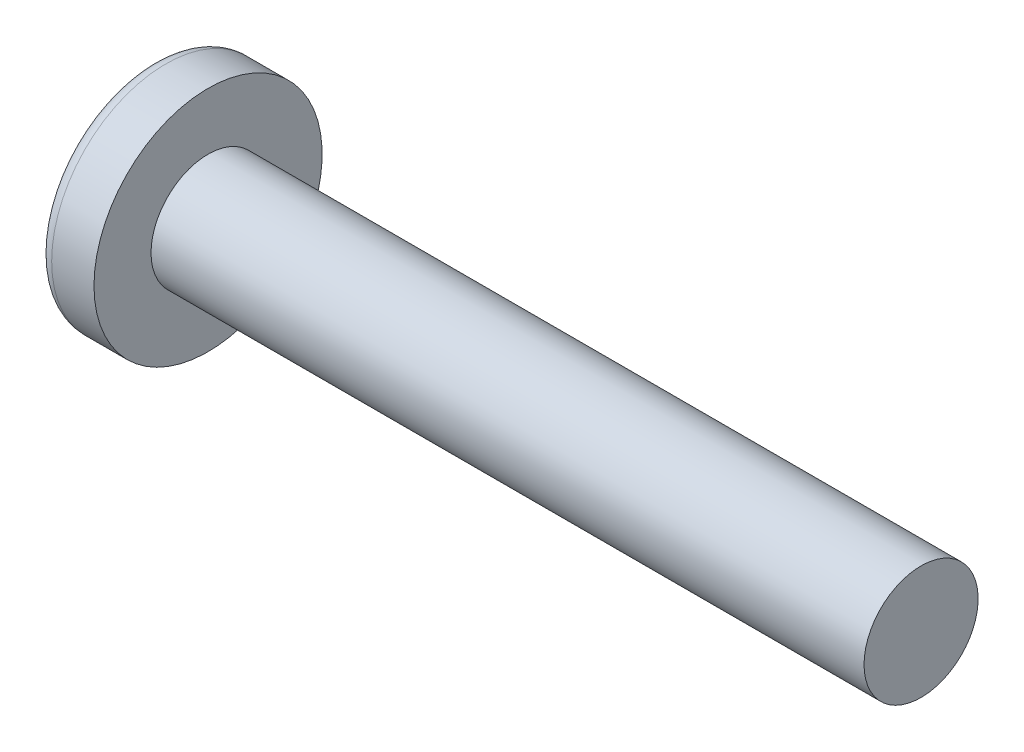
from build123d import *

# Parameters (mm, degrees)
SKETCH3_W         = 0.93
SKETCH3_H         = 4.4
SKETCH4_W         = 0.465
SKETCH4_H         = 0.465
CIRPATTERN1_COUNT = 2
CIRPATTERN1_ANGLE = 90


with BuildPart() as part:
    # BodySke → Base-Revolve (revolve)
    with BuildSketch(Plane.XY):
        with BuildLine():
            Line((3.1, 2), (3.1, 4))
            Line((3.1, 4), (1.616353821, 4))
            ThreePointArc((1.616353821, 4), (1.397629036, 3.947269784), (1.226960106, 3.800664452))
            ThreePointArc((1.226960106, 3.800664452), (0.314340807, 1.996902688), (0, 0))
            Line((0, 0), (28.1, 0))
            Line((28.1, 0), (28.1, 2))
            Line((28.1, 2), (3.1, 2))
        make_face()
    revolve(axis=Axis((-25.4, 0, 0), (1, 0, 0)))

    # Sketch3 → Cut-Loft1 section 0
    with BuildSketch(Plane(origin=(0, 0, 0), x_dir=(0, 0, -1), z_dir=(1, 0, 0))):
        Rectangle(SKETCH3_W, SKETCH3_H)
    # Sketch4 → Cut-Loft1 section 1
    with BuildSketch(Plane(origin=(2.45, 0, 0), x_dir=(0, 0, -1), z_dir=(1, 0, 0))):
        Rectangle(SKETCH4_W, SKETCH4_H)
    cut_loft1 = loft(mode=Mode.SUBTRACT)

    # CirPattern1: Cut-Loft1 ×2 about axis
    cirpattern1_axis = Axis((0, 0, 0), (1, 0, 0))
    for i in range(1, CIRPATTERN1_COUNT):
        add(cut_loft1.rotate(cirpattern1_axis, i * CIRPATTERN1_ANGLE / (CIRPATTERN1_COUNT - 1)), mode=Mode.SUBTRACT)


solid = part.part
